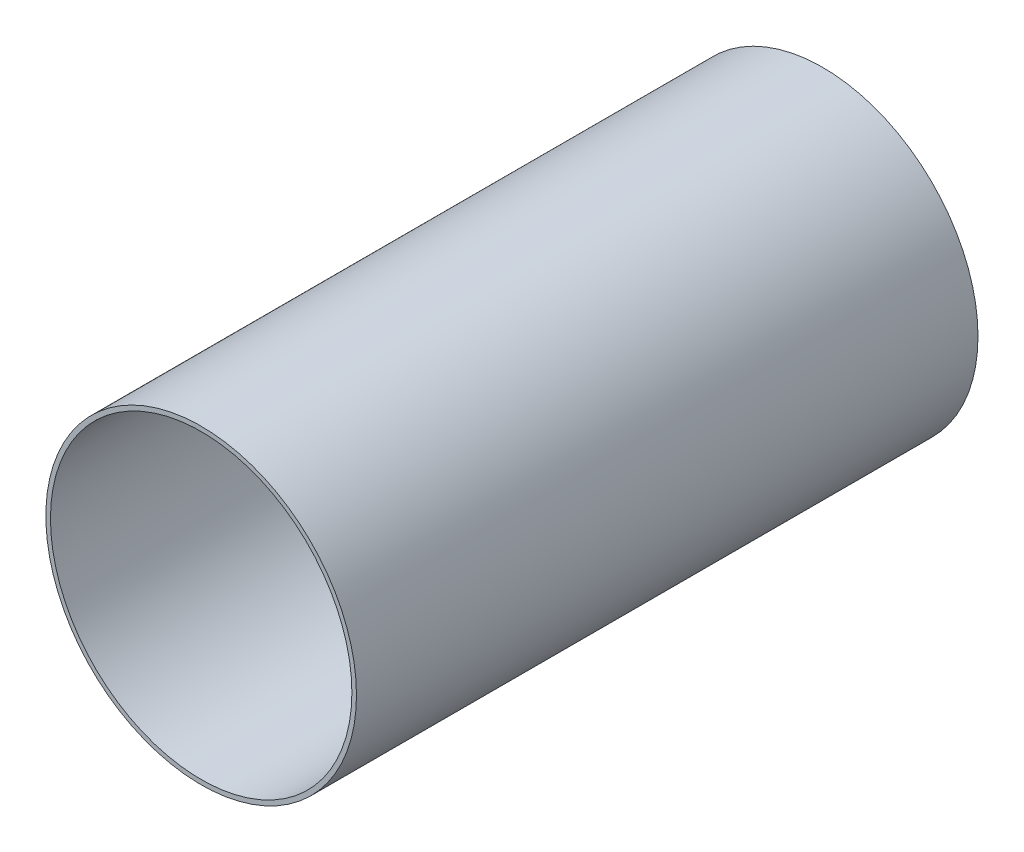
from build123d import *

# Parameters (mm, degrees)
SKETCH1_R           = 63.4746
SKETCH1_R_2         = 61.595
BOSS_EXTRUDE1_DEPTH = 127


with BuildPart() as part:
    # Sketch1 → Boss-Extrude1 (new body, symmetric)
    with BuildSketch(Plane.XY):
        Circle(SKETCH1_R)
        Circle(SKETCH1_R_2, mode=Mode.SUBTRACT)
    extrude(amount=BOSS_EXTRUDE1_DEPTH, both=True)


solid = part.part
